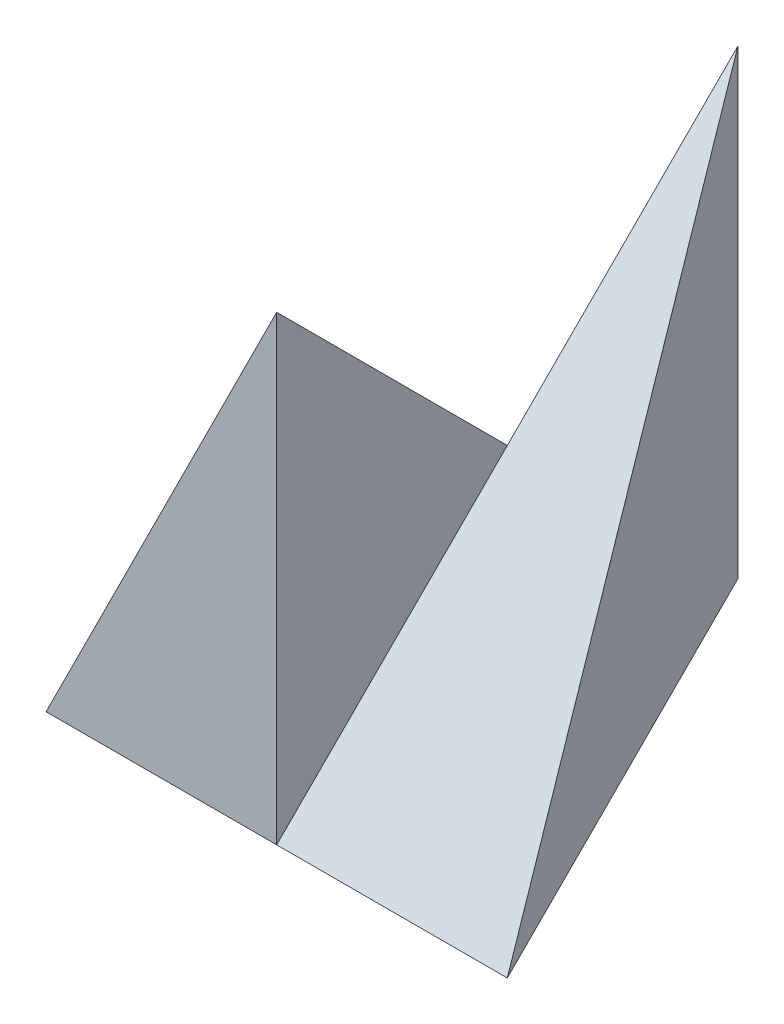
from build123d import *

# Parameters (mm, degrees)
SKETCH1_W           = 4
SKETCH1_H           = 4
BOSS_EXTRUDE1_DEPTH = 4
CUT_EXTRUDE1_DEPTH  = 2
CUT_EXTRUDE2_DEPTH  = 2
CUT_EXTRUDE3_DEPTH  = 10
CUT_EXTRUDE4_DEPTH  = 10


with BuildPart() as part:
    # Sketch1 → Boss-Extrude1 (new body)
    with BuildSketch(Plane(origin=(0, 0, 0), x_dir=(1, 0, 0), z_dir=(0, 1, 0))):
        Rectangle(SKETCH1_W, SKETCH1_H)
    extrude(amount=BOSS_EXTRUDE1_DEPTH)

    # Sketch2 → Cut-Extrude1 (cut)
    with BuildSketch(Plane.ZY.offset(2)):
        Polygon((2, 4), (-2, 0), (-2, 4), align=None)
    extrude(amount=-CUT_EXTRUDE1_DEPTH, mode=Mode.SUBTRACT)

    # Sketch3 → Cut-Extrude2 (cut)
    with BuildSketch(Plane(origin=(2, 0, 0), x_dir=(0, 0, -1), z_dir=(1, 0, 0))):
        Polygon((-2, 0), (2, 4), (-2, 4), align=None)
    extrude(amount=-CUT_EXTRUDE2_DEPTH, mode=Mode.SUBTRACT)

    # Sketch4 → Cut-Extrude3 (cut)
    with BuildSketch(Plane.XY.offset(2)):
        Polygon((-2, 0), (0, 4), (-2, 4), align=None)
        Polygon((2, 4), (0, 4), (2, 0), align=None)
    extrude(amount=-CUT_EXTRUDE3_DEPTH, mode=Mode.SUBTRACT)

    # Sketch5 → Cut-Extrude4 (cut)
    with BuildSketch(Plane.XZ):
        Polygon((2, 2), (0, -2), (2, -2), align=None)
        Polygon((0, -2), (-2, 2), (-2, -2), align=None)
    extrude(amount=-CUT_EXTRUDE4_DEPTH, mode=Mode.SUBTRACT)


solid = part.part
